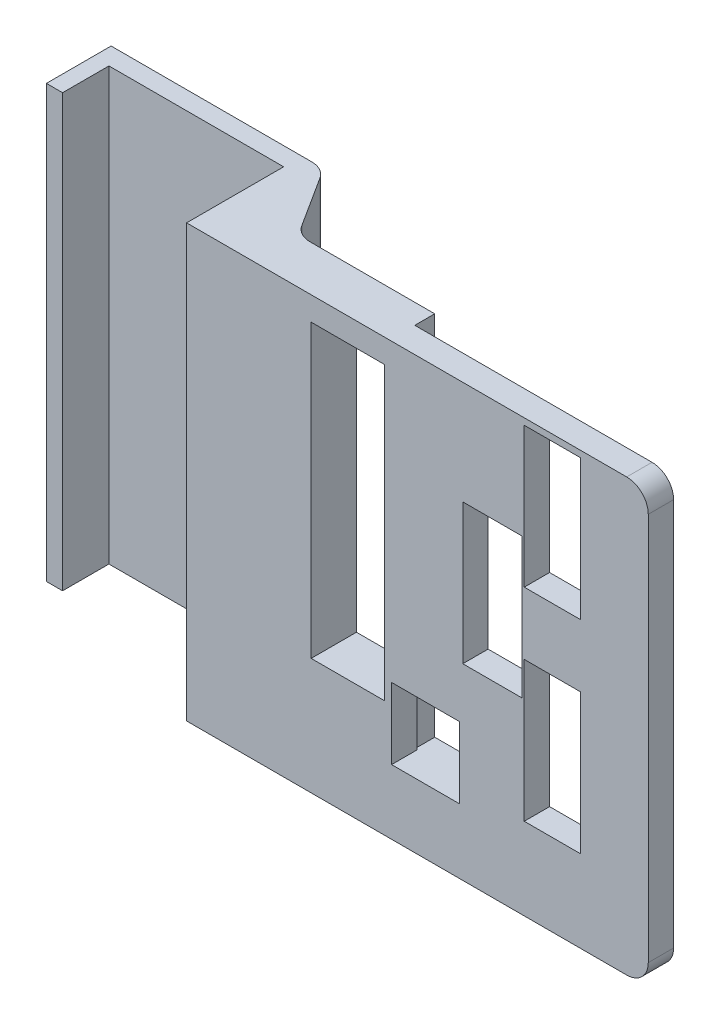
from build123d import *

# Parameters (mm, degrees)
BOSS_EXTRUDE1_DEPTH = 200
SKETCH2_W           = 34
SKETCH2_H           = 135
SKETCH2_W_2         = 26
SKETCH2_H_2         = 65
SKETCH2_W_3         = 27.5
SKETCH2_W_4         = 31.5
SKETCH2_H_3         = 33
CUT_EXTRUDE1_DEPTH  = 200
SKETCH3_W           = 32.5
SKETCH3_H           = 30
BOSS_EXTRUDE2_DEPTH = 9.25
FILLET1_R           = 10


with BuildPart() as part:
    # Sketch1 → Boss-Extrude1 (new body)
    with BuildSketch(Plane(origin=(0, 0, 0), x_dir=(1, 0, 0), z_dir=(0, 1, 0))):
        Polygon((-38, -10.75), (-45.5, -10.75), (-45.5, 19.25), (53, 19.25), (73.75, -13.25), (137.04, -13.25), (137.04, -22.5), (257.04, -22.5), (257.04, -34.25), (43, -34.25), (43, 10.75), (-38, 10.75), align=None)
    extrude(amount=BOSS_EXTRUDE1_DEPTH)

    # Sketch2 → Cut-Extrude1 (cut)
    with BuildSketch(Plane(origin=(0, 0, 13.25), x_dir=(-1, 0, 0), z_dir=(0, 0, -1))):
        with Locations((-117.75, 121.5)):
            Rectangle(SKETCH2_W, SKETCH2_H)
        with Locations((-212.54, 164.5)):
            Rectangle(SKETCH2_W_2, SKETCH2_H_2)
        with Locations((-212.54, 70.5)):
            Rectangle(SKETCH2_W_2, SKETCH2_H_2)
        with Locations((-184.79, 119.5)):
            Rectangle(SKETCH2_W_3, SKETCH2_H_2)
        with Locations((-153.79, 46.5)):
            Rectangle(SKETCH2_W_4, SKETCH2_H_3)
    extrude(amount=-CUT_EXTRUDE1_DEPTH, mode=Mode.SUBTRACT)

    # Sketch3 → Boss-Extrude2 (add)
    with BuildSketch(Plane(origin=(0, 0, 22.5), x_dir=(-1, 0, 0), z_dir=(0, 0, -1))):
        with Locations((-153.29, 15)):
            Rectangle(SKETCH3_W, SKETCH3_H)
    extrude(amount=BOSS_EXTRUDE2_DEPTH)

    # Fillet1
    fillet1_edges = [part.edges().sort_by_distance(p)[0] for p in [
        (257.04, 0, 28.375),
        (257.04, 200, 28.375),
        (53, 100, -19.25),
        (73.75, 100, 13.25),
    ]]
    fillet(fillet1_edges, radius=FILLET1_R)


solid = part.part
